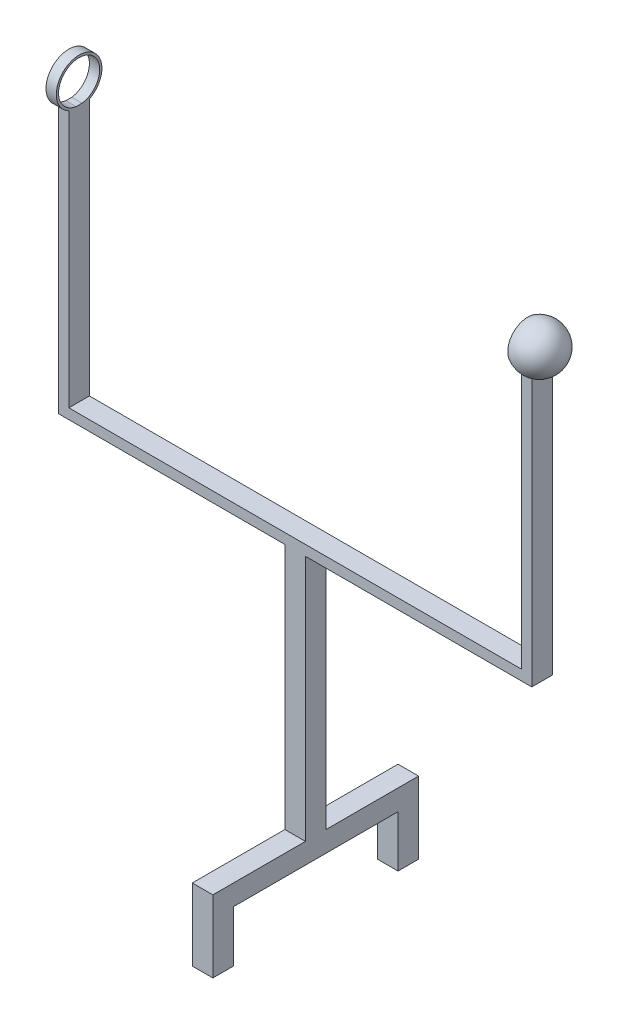
from build123d import *

# Parameters (mm, degrees)
BOSS_EXTRU_1_DEPTH = 2
ESQUISSE3_W        = 4
ESQUISSE3_H        = 4
BOSS_EXTRU_2_DEPTH = 20
ESQUISSE4_W        = 4
ESQUISSE4_H        = 4
BOSS_EXTRU_3_DEPTH = 10
ESQUISSE5_R        = 4.435199719
ESQUISSE5_R_2      = 4
BOSS_EXTRU_4_DEPTH = 2


with BuildPart() as part:
    # Esquisse1 → Boss.-Extru.1 (new body, symmetric)
    with BuildSketch(Plane.XY):
        Polygon((0, 0), (0, 50), (44, 50), (44, 100), (46, 100), (46, 48), (2, 48), (2, 0), align=None)
    boss_extru_1 = extrude(amount=BOSS_EXTRU_1_DEPTH, both=True)

    # Esquisse2 → R_volution1 (revolve)
    with BuildSketch(Plane.XY):
        with BuildLine():
            Line((43.480681174, 107.464101615), (43.230681174, 107.897114317))
            ThreePointArc((43.230681174, 107.897114317), (47.730681174, 107.897114317), (49.980681174, 104))
            Line((49.980681174, 104), (49.480681174, 104))
            ThreePointArc((49.480681174, 104), (47.480681174, 107.464101615), (43.480681174, 107.464101615))
        make_face()
    revolve(axis=Axis((49.980681174, 104, 0), (-1, 0, 0)))

    # Sym_trie1: Boss.-Extru.1 across plane
    add(boss_extru_1.mirror(Plane(origin=(0, 0, -2), x_dir=(0, 0, 1), z_dir=(-1, 0, 0))))

    # Esquisse3 → Boss.-Extru.2 (add)
    with BuildSketch(Plane.XY):
        with Locations((0, -2)):
            Rectangle(ESQUISSE3_W, ESQUISSE3_H)
    boss_extru_2 = extrude(amount=BOSS_EXTRU_2_DEPTH)

    # Esquisse4 → Boss.-Extru.3 (add)
    with BuildSketch(Plane(origin=(0, -4, 0), x_dir=(-1, 0, 0), z_dir=(0, -1, 0))):
        with Locations((0, -18)):
            Rectangle(ESQUISSE4_W, ESQUISSE4_H)
    boss_extru_3 = extrude(amount=BOSS_EXTRU_3_DEPTH)

    # Sym_trie2: Boss.-Extru.2, Boss.-Extru.3 across plane
    add(boss_extru_2.mirror(Plane(origin=(0, 0, 0), x_dir=(1, 0, 0), z_dir=(0, 0, -1))))
    add(boss_extru_3.mirror(Plane(origin=(0, 0, 0), x_dir=(1, 0, 0), z_dir=(0, 0, -1))))

    # Esquisse5 → Boss.-Extru.4 (add)
    with BuildSketch(Plane.ZY.offset(46)):
        with Locations((0, 103.958660954)):
            Circle(ESQUISSE5_R)
        with Locations((0, 103.958660954)):
            Circle(ESQUISSE5_R_2, mode=Mode.SUBTRACT)
    extrude(amount=-BOSS_EXTRU_4_DEPTH)


solid = part.part
